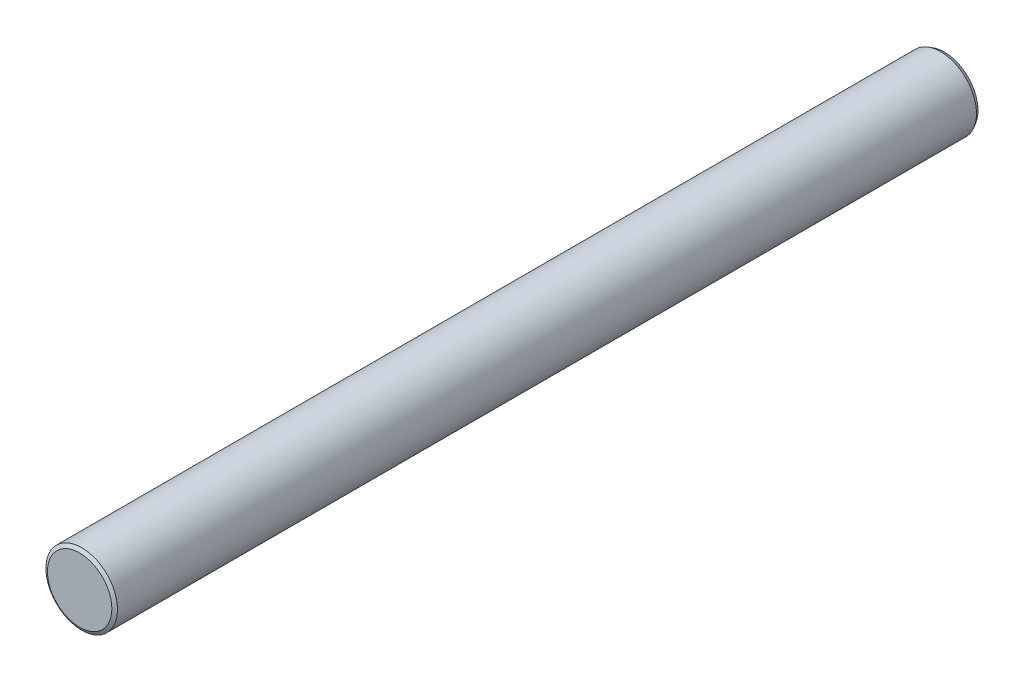
from build123d import *

# Parameters (mm, degrees)
SKETCH1_R             = 3.475
BOSS_EXTRUDE1_DEPTH   = 42
CHAMFER1_SIZE         = 0.2
CHAMFER1_SIZE2        = 0.346410162
CHAMFER1_PART_2_SIZE  = 0.2
CHAMFER1_PART_2_SIZE2 = 0.346410162


with BuildPart() as part:
    # Sketch1 → Boss-Extrude1 (new body, symmetric)
    with BuildSketch(Plane.XY):
        Circle(SKETCH1_R)
    extrude(amount=BOSS_EXTRUDE1_DEPTH, both=True)

    # Chamfer1
    chamfer1_edges = [part.edges().sort_by_distance(p)[0] for p in [
        (-3.475, 0, -42),
    ]]
    chamfer1_side = [part.faces().sort_by_distance(p)[0] for p in [
        (0, 0, -42),
    ]]
    chamfer(chamfer1_edges, length=CHAMFER1_SIZE, length2=CHAMFER1_SIZE2, reference=chamfer1_side[0])

    # Chamfer1 part 2
    chamfer1_part_2_edges = [part.edges().sort_by_distance(p)[0] for p in [
        (-3.475, 0, 42),
    ]]
    chamfer1_part_2_side = [part.faces().sort_by_distance(p)[0] for p in [
        (-3.475, 0, 0),
    ]]
    chamfer(chamfer1_part_2_edges, length=CHAMFER1_PART_2_SIZE, length2=CHAMFER1_PART_2_SIZE2, reference=chamfer1_part_2_side[0])


solid = part.part
